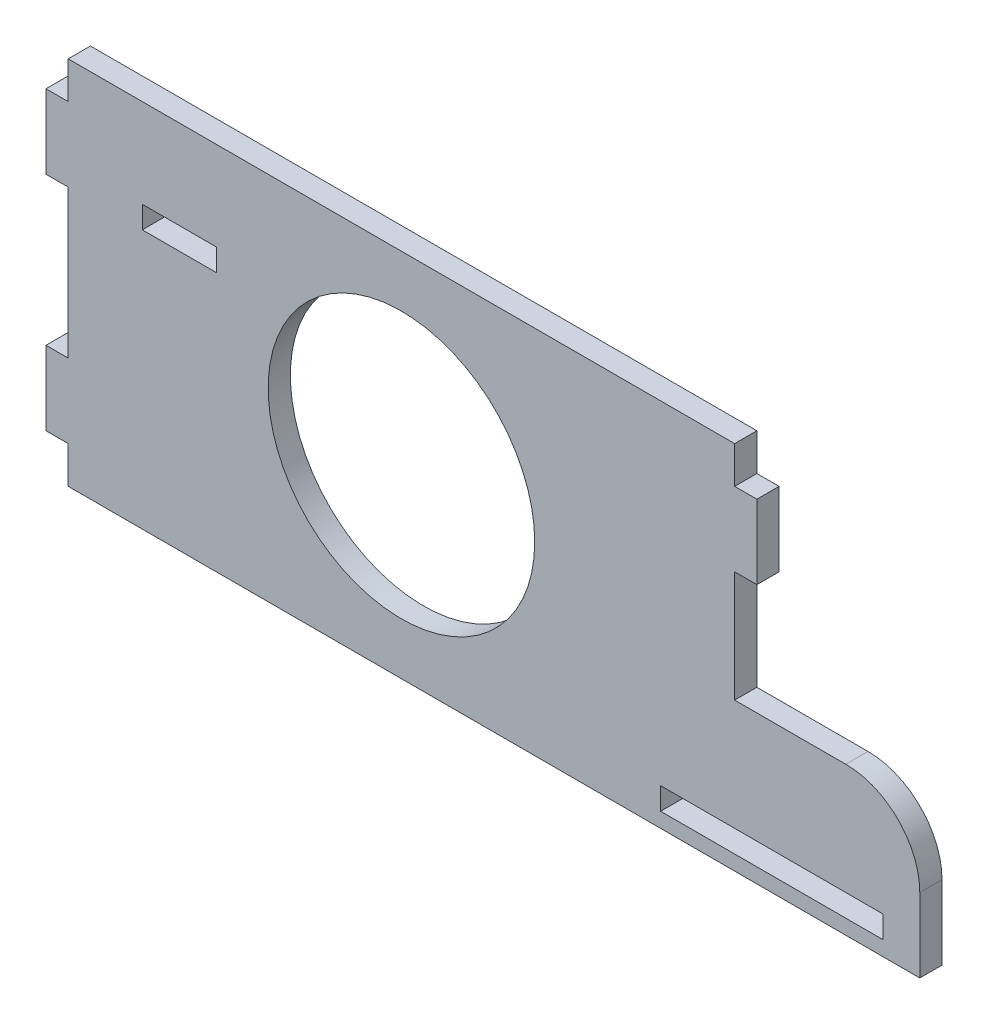
from build123d import *

# Parameters (mm, degrees)
SKETCH1_R           = 18
SKETCH1_W           = 10
SKETCH1_H           = 3
SKETCH1_W_2         = 30
BOSS_EXTRUDE1_DEPTH = 3


with BuildPart() as part:
    # Sketch1 → Boss-Extrude1 (new body)
    with BuildSketch(Plane.XY):
        with BuildLine():
            Line((-45, 10), (-45, -10))
            Line((-45, -10), (-48, -10))
            Line((-48, -10), (-48, -20))
            Line((-48, -20), (-45, -20))
            Line((-45, -20), (-45, -25))
            Line((-45, -25), (70, -25))
            Line((70, -25), (70, -15))
            ThreePointArc((70, -15), (67.071067812, -7.928932188), (60, -5))
            Line((60, -5), (45, -5))
            Line((45, -5), (45, 10))
            Line((45, 10), (48, 10))
            Line((48, 10), (48, 20))
            Line((48, 20), (45, 20))
            Line((45, 20), (45, 25))
            Line((45, 25), (-45, 25))
            Line((-45, 25), (-45, 20))
            Line((-45, 20), (-48, 20))
            Line((-48, 20), (-48, 10))
            Line((-48, 10), (-45, 10))
        make_face()
        Circle(SKETCH1_R, mode=Mode.SUBTRACT)
        with Locations((-30, 11.5)):
            Rectangle(SKETCH1_W, SKETCH1_H, mode=Mode.SUBTRACT)
        with Locations((50, -21.5)):
            Rectangle(SKETCH1_W_2, SKETCH1_H, mode=Mode.SUBTRACT)
    extrude(amount=BOSS_EXTRUDE1_DEPTH)


solid = part.part
